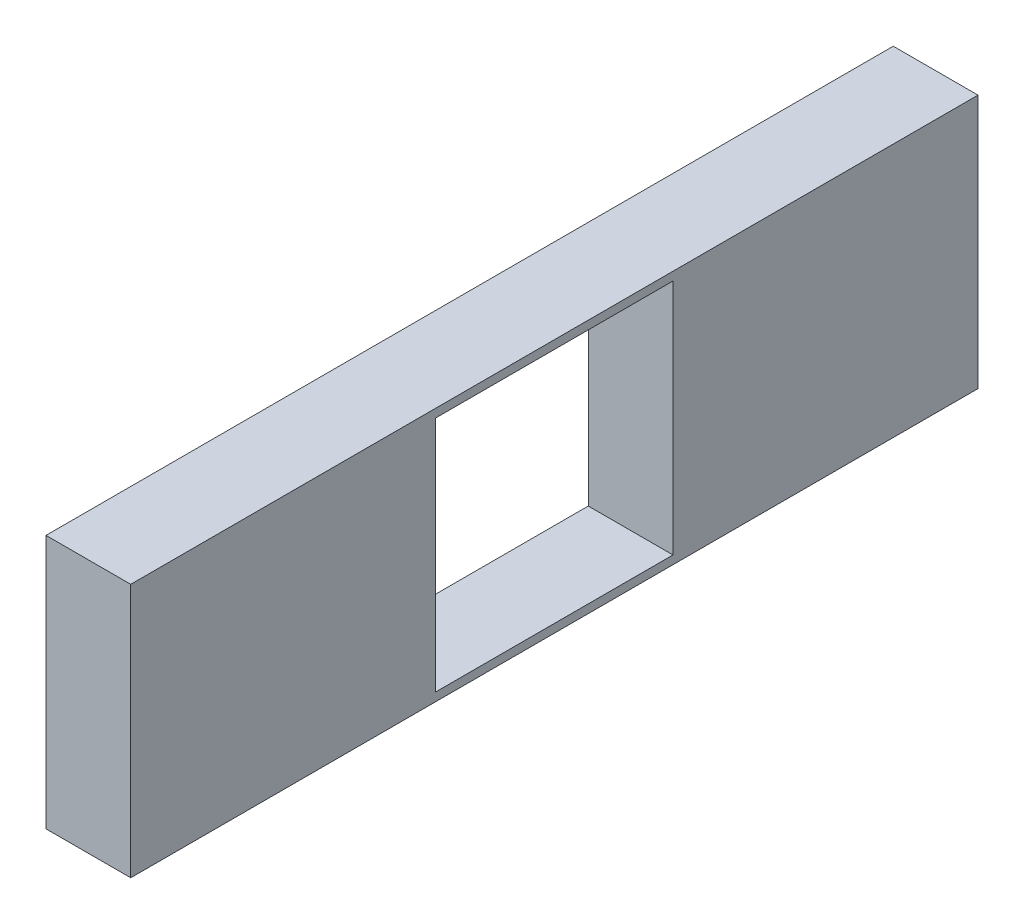
from build123d import *

# Parameters (mm, degrees)
SKETCH1_W           = 14
SKETCH1_H           = 14
BOSS_EXTRUDE1_DEPTH = 5


with BuildPart() as part:
    # Sketch1 → Boss-Extrude1 (new body)
    with BuildSketch(Plane(origin=(0, 0, 0), x_dir=(0, 0, -1), z_dir=(1, 0, 0))):
        Polygon((50, 15), (18, 15), (0, 15), (0, 0), (50, 0), align=None)
        with Locations((25, 7.5)):
            Rectangle(SKETCH1_W, SKETCH1_H, mode=Mode.SUBTRACT)
    extrude(amount=BOSS_EXTRUDE1_DEPTH)


solid = part.part
